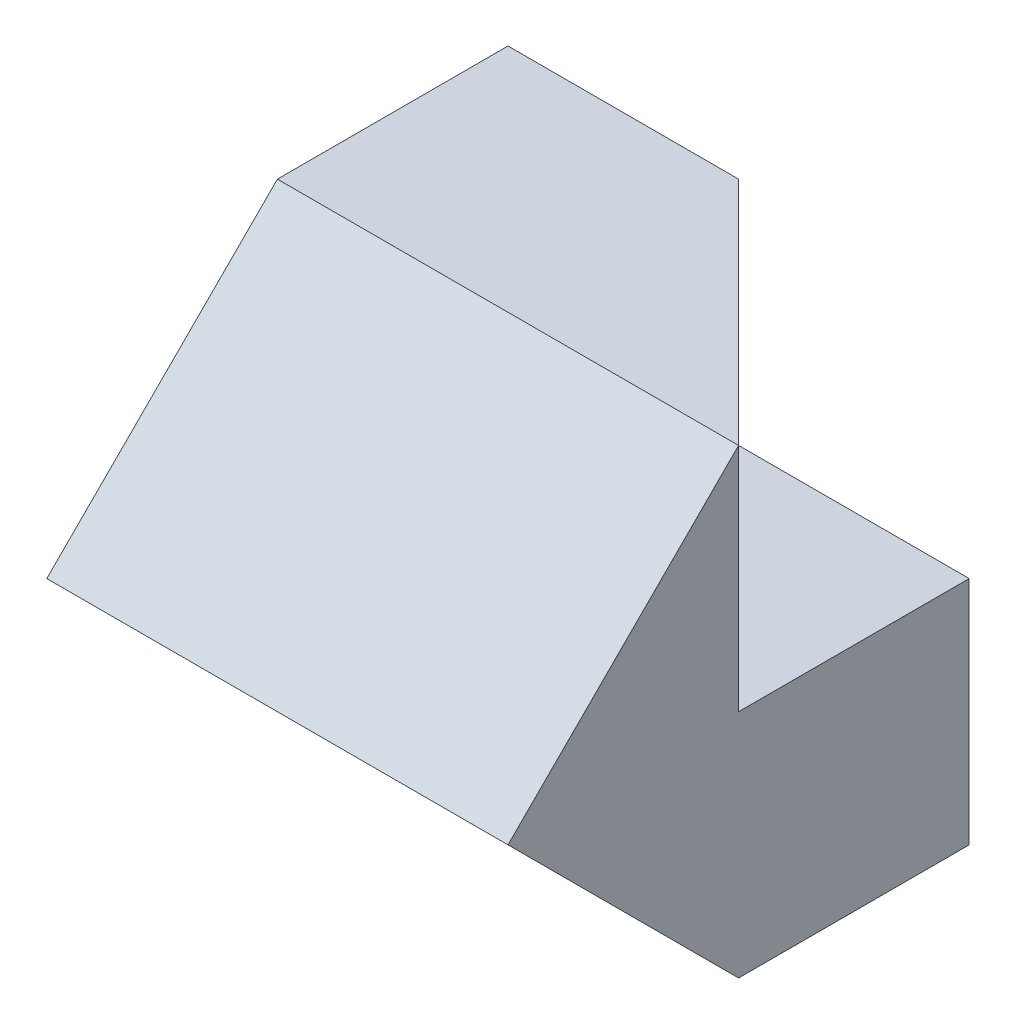
from build123d import *

# Parameters (mm, degrees)
BOSS_EXTRUDE1_DEPTH = 4
CUT_EXTRUDE1_DEPTH  = 4
CUT_EXTRUDE2_DEPTH  = 2


with BuildPart() as part:
    # Sketch1 → Boss-Extrude1 (new body)
    with BuildSketch(Plane.XY):
        Polygon((0, 0), (0, 2), (-2, 2), (-2, 4), (2, 4), (2, 0), align=None)
    extrude(amount=BOSS_EXTRUDE1_DEPTH)

    # Sketch2 → Cut-Extrude1 (cut)
    with BuildSketch(Plane.ZY.offset(2)):
        Polygon((4, 4), (2, 4), (4, 2), align=None)
        Polygon((4, 0), (4, 2), (2, 0), align=None)
    extrude(amount=-CUT_EXTRUDE1_DEPTH, mode=Mode.SUBTRACT)

    # Sketch3 → Cut-Extrude2 (cut)
    with BuildSketch(Plane(origin=(0, 4, 0), x_dir=(1, 0, 0), z_dir=(0, 1, 0))):
        Polygon((2, -2), (0, 0), (2, 0), align=None)
    extrude(amount=-CUT_EXTRUDE2_DEPTH, mode=Mode.SUBTRACT)


solid = part.part
